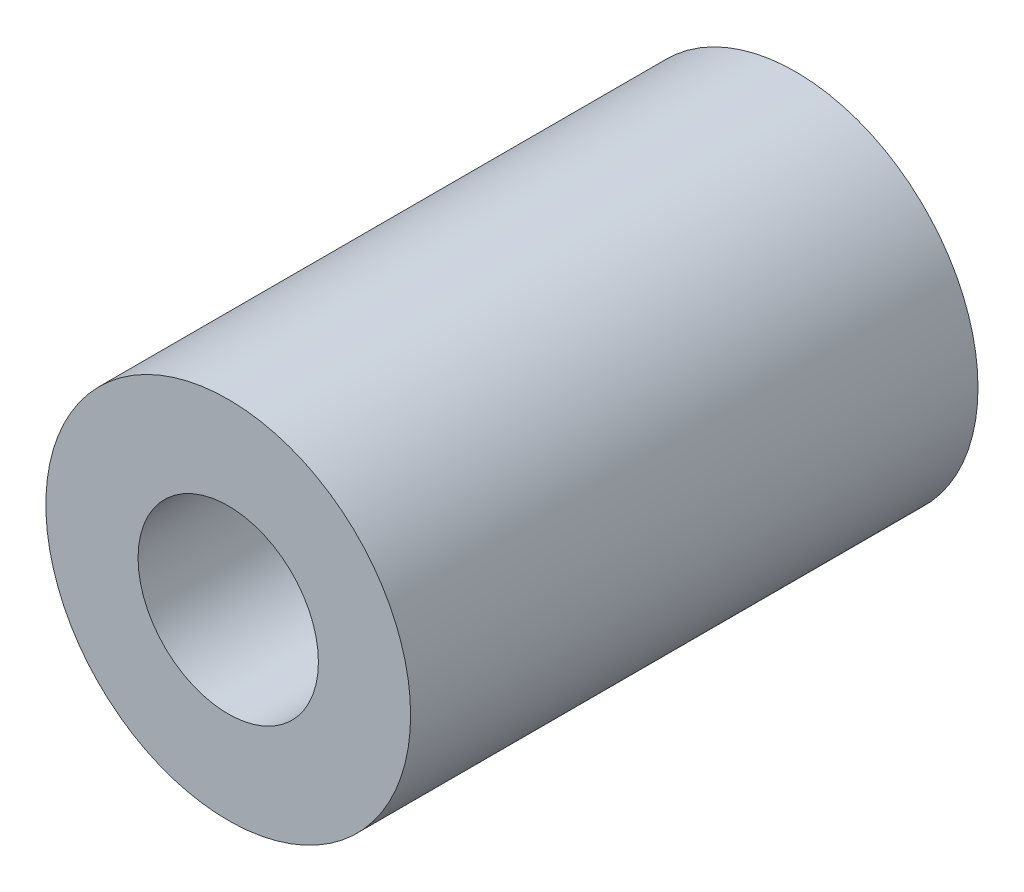
from build123d import *

# Parameters (mm, degrees)
SKETCH1_R           = 9
SKETCH1_R_2         = 5.1
BOSS_EXTRUDE1_DEPTH = 16
SKETCH2_R           = 9
BOSS_EXTRUDE2_DEPTH = 12
SKETCH5_R           = 4.45
CUT_EXTRUDE1_DEPTH  = 8


with BuildPart() as part:
    # Sketch1 → Boss-Extrude1 (new body)
    with BuildSketch(Plane.XY):
        Circle(SKETCH1_R)
        Circle(SKETCH1_R_2, mode=Mode.SUBTRACT)
    extrude(amount=BOSS_EXTRUDE1_DEPTH)

    # Sketch2 → Boss-Extrude2 (add)
    with BuildSketch(Plane.XY.offset(16)):
        Circle(SKETCH2_R)
    extrude(amount=BOSS_EXTRUDE2_DEPTH)

    # Sketch5 → Cut-Extrude1 (cut)
    with BuildSketch(Plane.XY.offset(28)):
        Circle(SKETCH5_R)
    extrude(amount=-CUT_EXTRUDE1_DEPTH, mode=Mode.SUBTRACT)


solid = part.part
